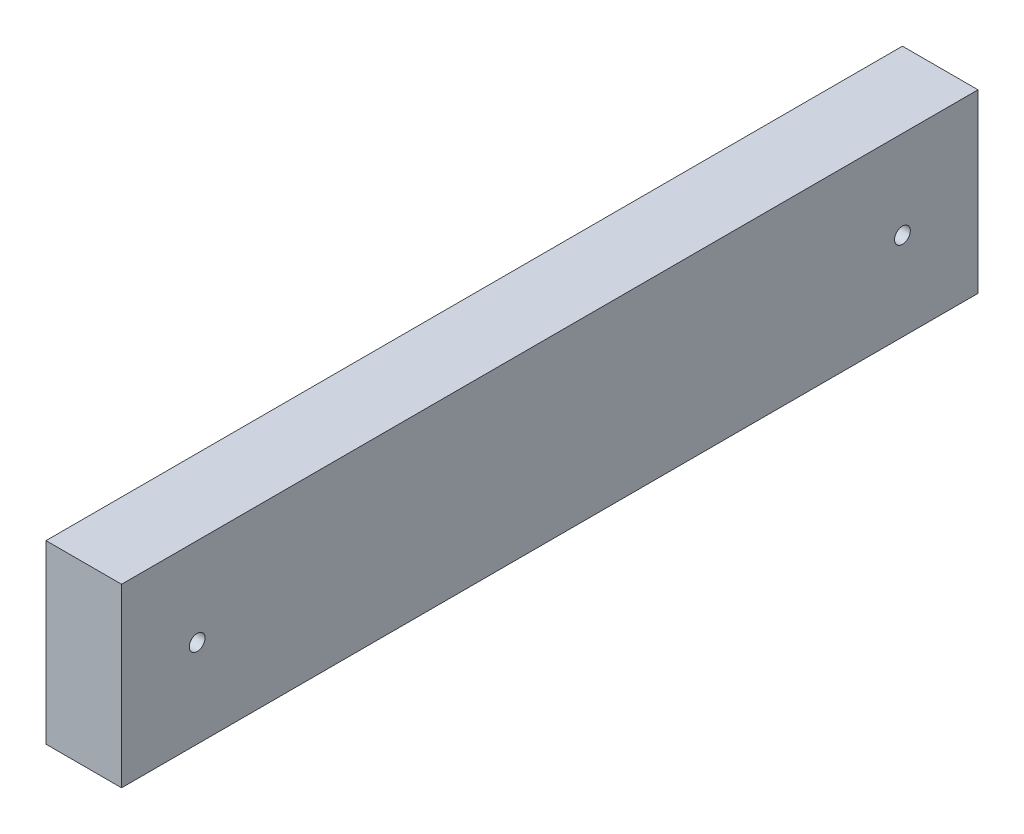
from build123d import *

# Parameters (mm, degrees)
SKETCH1_W                      = 38.1
SKETCH1_H                      = 88.9
BOSS_EXTRUDE1_DEPTH            = 431.8
F_5_16_0_3125_DIAMETER_HOLE1_D = 7.9375


with BuildPart() as part:
    # Sketch1 → Boss-Extrude1 (new body)
    with BuildSketch(Plane.XY):
        Rectangle(SKETCH1_W, SKETCH1_H)
    extrude(amount=BOSS_EXTRUDE1_DEPTH)

    # 5/16 (0.3125) Diameter Hole1 (through all)
    with Locations(Plane(origin=(19.05, 0, 0), x_dir=(0, 0, -1), z_dir=(1, 0, 0))):
        with Locations((-393.7, 0), (-38.1, 0)):
            Hole(F_5_16_0_3125_DIAMETER_HOLE1_D / 2)


solid = part.part
